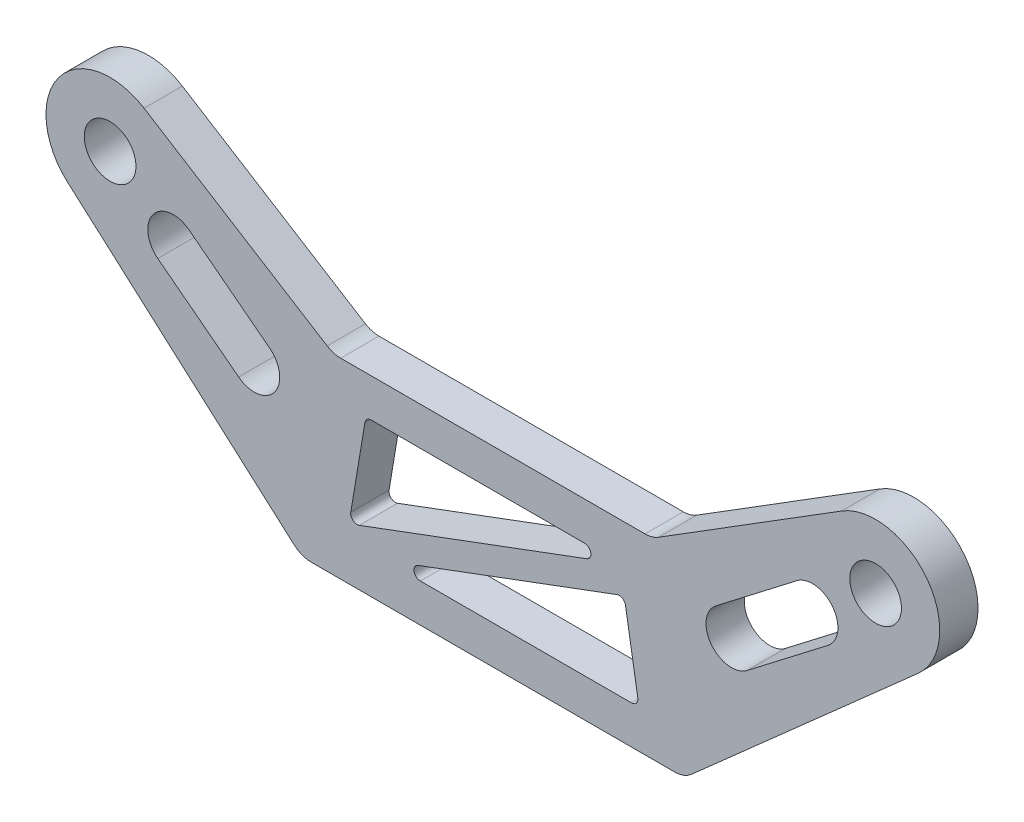
from build123d import *

# Parameters (mm, degrees)
SKETCH_1_R          = 2.025
EXTRUDE_1_DEPTH     = 3
CUT_EXTRUDE_1_DEPTH = 13
FILLET_1_R          = 0.5
FILLET_2_R          = 2


with BuildPart() as part:
    # 草图1 → 凸台-拉伸1 (new body)
    with BuildSketch(Plane.XY):
        with BuildLine():
            Line((-12.5, -5), (-27.339189471, 4.262711851))
            ThreePointArc((-27.339189471, 4.262711851), (-34.026108353, 3.006838294), (-33.33194179, -3.761487592))
            Line((-33.33194179, -3.761487592), (-15, -20))
            Line((-15, -20), (15, -20))
            Line((15, -20), (33.33194179, -3.761487592))
            ThreePointArc((33.33194179, -3.761487592), (34.026108353, 3.006838294), (27.339189471, 4.262711851))
            Line((27.339189471, 4.262711851), (12.5, -5))
            Line((12.5, -5), (-12.5, -5))
        make_face()
        with Locations((-30, 0)):
            Circle(SKETCH_1_R, mode=Mode.SUBTRACT)
        with Locations((30, 0)):
            Circle(SKETCH_1_R, mode=Mode.SUBTRACT)
    extrude(amount=EXTRUDE_1_DEPTH)

    # 草图2 → 切除-拉伸1 (cut)
    with BuildSketch(Plane.XY.offset(3)):
        Polygon((9.958618735, -8), (-9.958618735, -8), (-11.278048465, -15.916578379), align=None)
        Polygon((10.293550357, -10.009589734), (-8.458618735, -17), (11.458618735, -17), align=None)
        with BuildLine():
            Line((17.485082522, -7.103595065), (23.826074435, -2.225908978))
            ThreePointArc((23.826074435, -2.225908978), (26.630743935, -2.591735435), (26.264917478, -5.396404935))
            Line((26.264917478, -5.396404935), (19.923925565, -10.274091022))
            ThreePointArc((19.923925565, -10.274091022), (17.119256065, -9.908264565), (17.485082522, -7.103595065))
        make_face()
        with BuildLine():
            Line((-23.826074435, -2.225908978), (-17.485082522, -7.103595065))
            ThreePointArc((-17.485082522, -7.103595065), (-17.119256065, -9.908264565), (-19.923925565, -10.274091022))
            Line((-19.923925565, -10.274091022), (-26.264917478, -5.396404935))
            ThreePointArc((-26.264917478, -5.396404935), (-26.630743935, -2.591735435), (-23.826074435, -2.225908978))
        make_face()
    extrude(amount=-CUT_EXTRUDE_1_DEPTH, mode=Mode.SUBTRACT)

    # 圆角1
    fillet_1_edges = [part.edges().sort_by_distance(p)[0] for p in [
        (11.458618735, -17, 1.5),
        (-8.458618735, -17, 1.5),
        (10.293550357, -10.009589734, 1.5),
        (-11.278048465, -15.916578379, 1.5),
        (-9.958618735, -8, 1.5),
        (9.958618735, -8, 1.5),
    ]]
    fillet(fillet_1_edges, radius=FILLET_1_R)

    # 圆角2
    fillet_2_edges = [part.edges().sort_by_distance(p)[0] for p in [
        (-12.5, -5, 1.5),
        (12.5, -5, 1.5),
        (15, -20, 1.5),
        (-15, -20, 1.5),
    ]]
    fillet(fillet_2_edges, radius=FILLET_2_R)


solid = part.part
